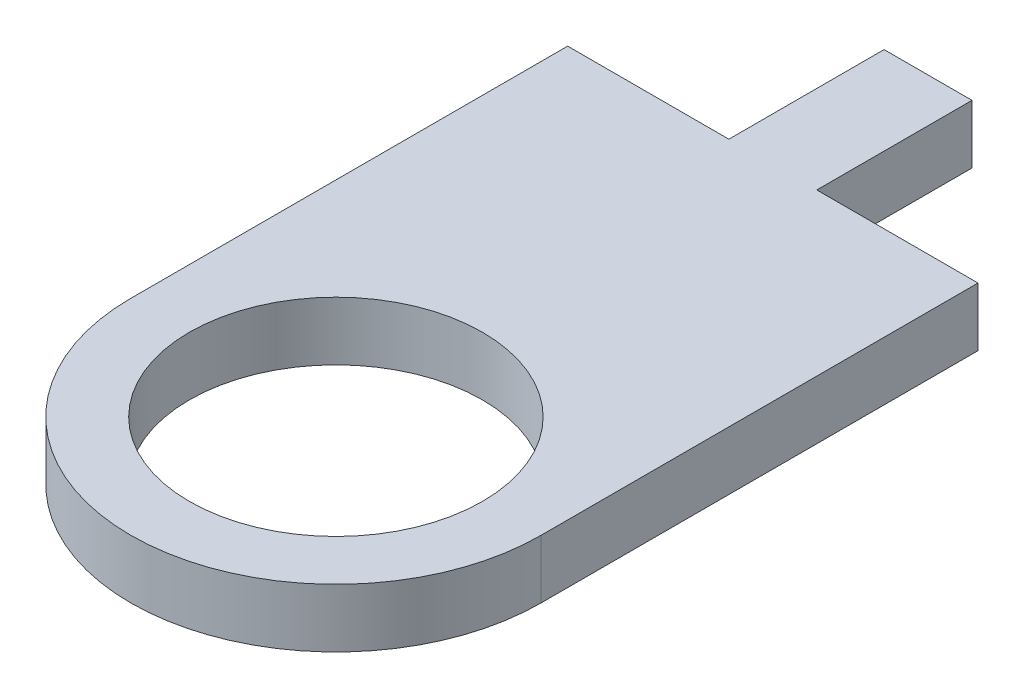
from build123d import *

# Parameters (mm, degrees)
SKETCH1_R           = 25
BOSS_EXTRUDE2_DEPTH = 10


with BuildPart() as part:
    # Sketch1 → Boss-Extrude2 (new body)
    with BuildSketch(Plane(origin=(0, 0, 0), x_dir=(1, 0, 0), z_dir=(0, 1, 0))):
        with BuildLine():
            Line((-35, 74.53460287), (-35, 0))
            ThreePointArc((-35, 0), (0, -35), (35, 0))
            Line((35, 0), (35, 74.53460287))
            Line((35, 74.53460287), (7.5, 74.53460287))
            Line((7.5, 74.53460287), (7.5, 101.011615082))
            Line((7.5, 101.011615082), (-7.5, 101.011615082))
            Line((-7.5, 101.011615082), (-7.5, 74.53460287))
            Line((-7.5, 74.53460287), (-35, 74.53460287))
        make_face()
        Circle(SKETCH1_R, mode=Mode.SUBTRACT)
    extrude(amount=BOSS_EXTRUDE2_DEPTH)


solid = part.part
